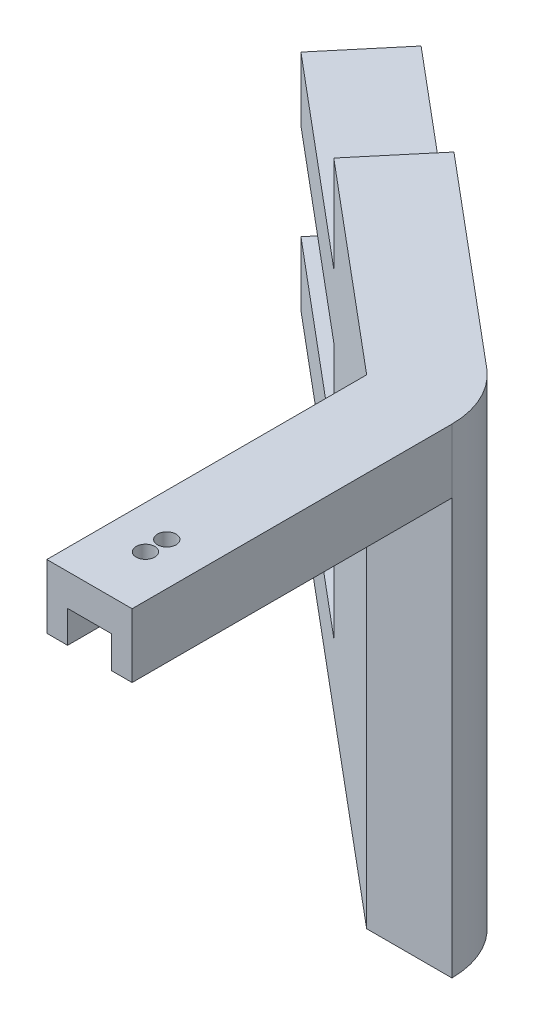
from build123d import *

# Parameters (mm, degrees)
SKETCH_1_W          = 16
SKETCH_1_H          = 60
EXTRUDE_1_DEPTH     = 12
EXTRUDE_2_DEPTH     = 90
SKETCH_3_W          = 16
SKETCH_3_H          = 18
CUT_EXTRUDE_2_DEPTH = 50
CUT_EXTRUDE_START   = -6
CUT_EXTRUDE_3_DEPTH = 6
SKETCH_2_4_R        = 1.75
CUT_EXTRUDE_4_DEPTH = 12


with BuildPart() as part:
    # 草图1 → 凸台-拉伸1 (new body)
    with BuildSketch(Plane(origin=(0, 0, 0), x_dir=(1, 0, 0), z_dir=(0, 1, 0))):
        Rectangle(SKETCH_1_W, SKETCH_1_H)
    extrude(amount=-EXTRUDE_1_DEPTH)

    # 草图1<4> → 凸台-拉伸2 (add)
    with BuildSketch(Plane(origin=(0, 0, 0), x_dir=(1, 0, 0), z_dir=(0, 1, 0))):
        with BuildLine():
            Line((-84.604444312, 94.278760969), (-8, 30))
            Line((-8, 30), (8, 30))
            ThreePointArc((8, 30), (6.500924593, 36.761892188), (2.284601755, 42.25671109))
            Line((2.284601755, 42.25671109), (-74.319842557, 106.535472059))
            Line((-74.319842557, 106.535472059), (-84.604444312, 94.278760969))
        make_face()
    extrude(amount=-EXTRUDE_2_DEPTH)

    # 草图3 → 切除-拉伸2 (cut)
    with BuildSketch(Plane(origin=(-96.071153318, 0, -80.613269316), x_dir=(-0.6427876096865492, 0, 0.7660444431189698), z_dir=(-0.7660444431189698, 0, -0.6427876096865492))):
        with Locations((-25.839032416, -9)):
            Rectangle(SKETCH_3_W, SKETCH_3_H)
        with Locations((-25.839032416, -39)):
            Rectangle(SKETCH_3_W, SKETCH_3_H)
        with Locations((-25.839032416, -69)):
            Rectangle(SKETCH_3_W, SKETCH_3_H)
    extrude(amount=-CUT_EXTRUDE_2_DEPTH, mode=Mode.SUBTRACT)

    # 草图2 → 切除-拉伸3 (cut)
    with BuildSketch(Plane(origin=(0, 0, 0), x_dir=(1, 0, 0), z_dir=(0, 1, 0)).offset(CUT_EXTRUDE_START)):
        Polygon((-4.1, -30), (0, -30), (4.1, -30), (4.1, -10), (-4.1, -10), align=None)
        with BuildLine():
            ThreePointArc((1.75, -19.5), (1.237436867, -20.737436867), (0, -21.25))
            ThreePointArc((0, -21.25), (-1.75, -19.5), (0, -17.75))
            ThreePointArc((0, -17.75), (1.237436867, -18.262563133), (1.75, -19.5))
        make_face(mode=Mode.SUBTRACT)
        with BuildLine():
            ThreePointArc((1.75, -15.5), (1.237436867, -16.737436867), (0, -17.25))
            ThreePointArc((0, -17.25), (-1.237436867, -14.262563133), (1.75, -15.5))
        make_face(mode=Mode.SUBTRACT)
    extrude(amount=-CUT_EXTRUDE_3_DEPTH, mode=Mode.SUBTRACT)

    # 草图2<4> → 切除-拉伸4 (cut)
    with BuildSketch(Plane(origin=(0, 0, 0), x_dir=(1, 0, 0), z_dir=(0, 1, 0))):
        with Locations((0, -15.5)):
            Circle(SKETCH_2_4_R)
        with Locations((0, -19.5)):
            Circle(SKETCH_2_4_R)
    extrude(amount=-CUT_EXTRUDE_4_DEPTH, mode=Mode.SUBTRACT)


solid = part.part
